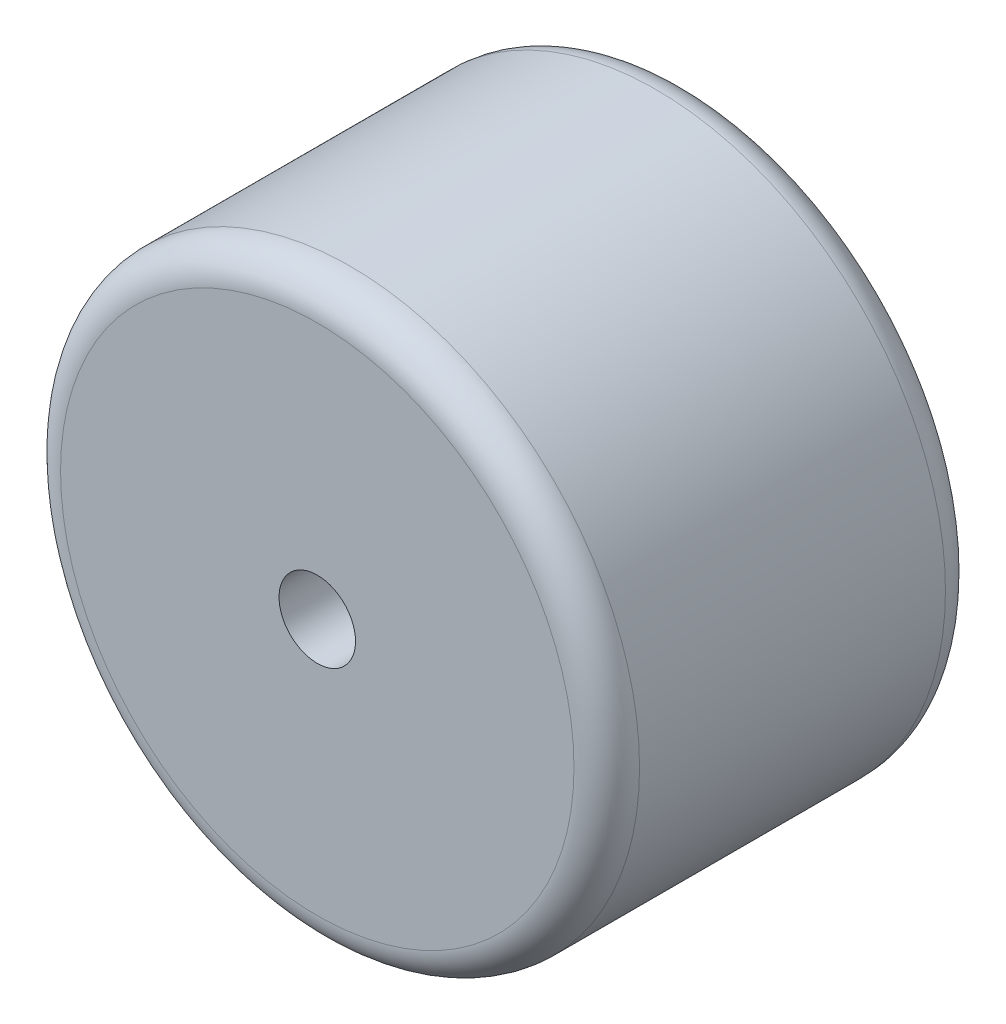
from build123d import *

# Parameters (mm, degrees)
SKETCH1_R           = 26.5
BOSS_EXTRUDE1_DEPTH = 34
FILLET1_R           = 3
CUT_EXTRUDE1_REACH  = 36
SKETCH2_R           = 3.5


with BuildPart() as part:
    # Sketch1 → Boss-Extrude1 (new body)
    with BuildSketch(Plane.XY):
        Circle(SKETCH1_R)
    extrude(amount=BOSS_EXTRUDE1_DEPTH)

    # Fillet1
    fillet1_edges = [part.edges().sort_by_distance(p)[0] for p in [
        (-26.5, 0, 0),
        (-26.5, 0, 34),
    ]]
    fillet(fillet1_edges, radius=FILLET1_R)

    # Sketch2 → Cut-Extrude1 (cut, up to next)
    with BuildSketch(Plane.XY.offset(34), mode=Mode.PRIVATE) as cut_extrude1_sk1:
        Circle(SKETCH2_R)
    cut_extrude1_tool1 = extrude(cut_extrude1_sk1.sketch, amount=-CUT_EXTRUDE1_REACH, mode=Mode.PRIVATE) & part.part
    add(cut_extrude1_tool1.solids().sort_by_distance((0, 0, 34))[0], mode=Mode.SUBTRACT)


solid = part.part
